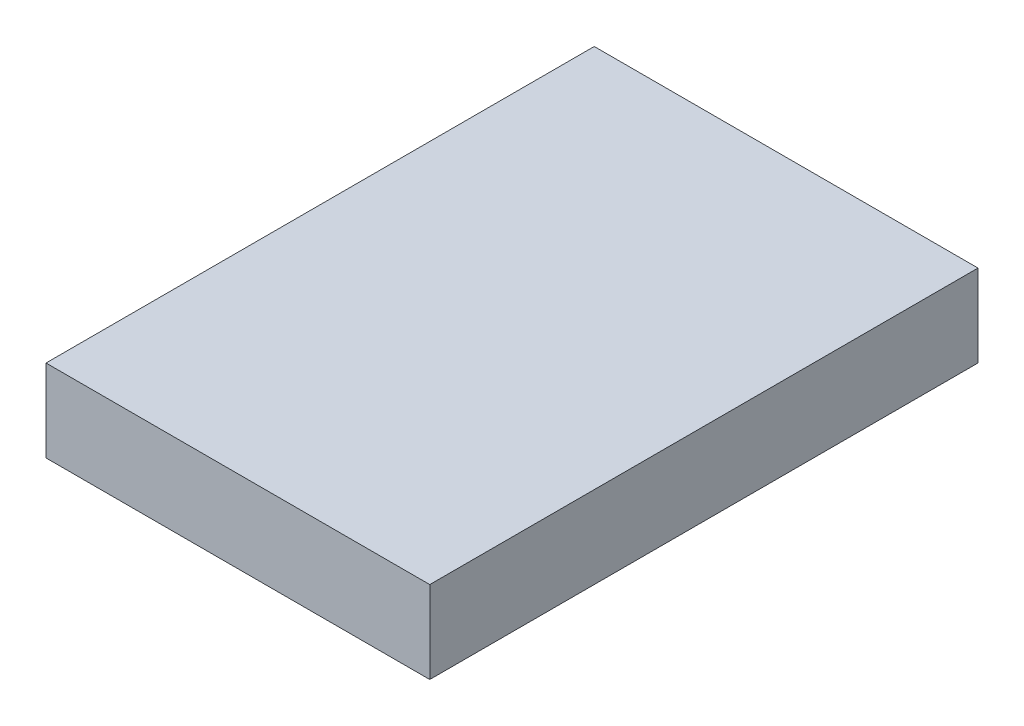
from build123d import *

# Parameters (mm, degrees)
SKETCH2_W           = 70
SKETCH2_H           = 100
BOSS_EXTRUDE1_DEPTH = 15


with BuildPart() as part:
    # Sketch2 → Boss-Extrude1 (new body)
    with BuildSketch(Plane(origin=(0, 0, 0), x_dir=(1, 0, 0), z_dir=(0, 1, 0))):
        Rectangle(SKETCH2_W, SKETCH2_H)
    extrude(amount=BOSS_EXTRUDE1_DEPTH)


solid = part.part
